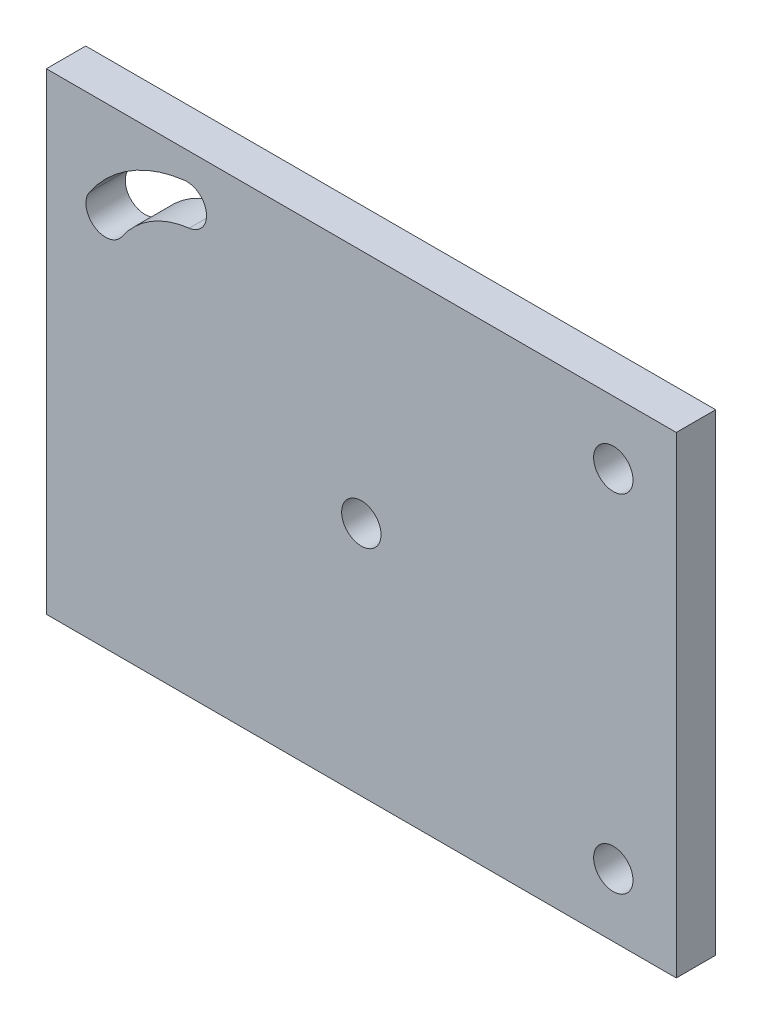
from build123d import *

# Parameters (mm, degrees)
SKETCH1_W           = 80
SKETCH1_H           = 60
SKETCH1_R           = 2.5
BOSS_EXTRUDE1_DEPTH = 5
SKETCH2_R           = 2.5
CUT_EXTRUDE1_DEPTH  = 6


with BuildPart() as part:
    # Sketch1 → Boss-Extrude1 (new body)
    with BuildSketch(Plane.XY):
        with Locations((40, -30)):
            Rectangle(SKETCH1_W, SKETCH1_H)
        with Locations((40, -30)):
            Circle(SKETCH1_R, mode=Mode.SUBTRACT)
    extrude(amount=BOSS_EXTRUDE1_DEPTH)

    # Sketch2 → Cut-Extrude1 (cut, through all)
    with BuildSketch(Plane.XY.offset(5)):
        with Locations((72, -52)):
            Circle(SKETCH2_R)
        with Locations((72, -8)):
            Circle(SKETCH2_R)
        with BuildLine():
            ThreePointArc((17.552814057, -3.5), (10.699313896, -5.865002188), (5.454493121, -10.87055459))
            ThreePointArc((5.454493121, -10.87055459), (6.127589233, -14.341425031), (9.598459675, -13.66832892))
            ThreePointArc((9.598459675, -13.66832892), (13.300686104, -10.134997812), (18.138450924, -8.465584503))
            ThreePointArc((18.138450924, -8.465584503), (20.328424742, -5.689973818), (17.552814057, -3.5))
        make_face()
    extrude(amount=-CUT_EXTRUDE1_DEPTH, mode=Mode.SUBTRACT)


solid = part.part
